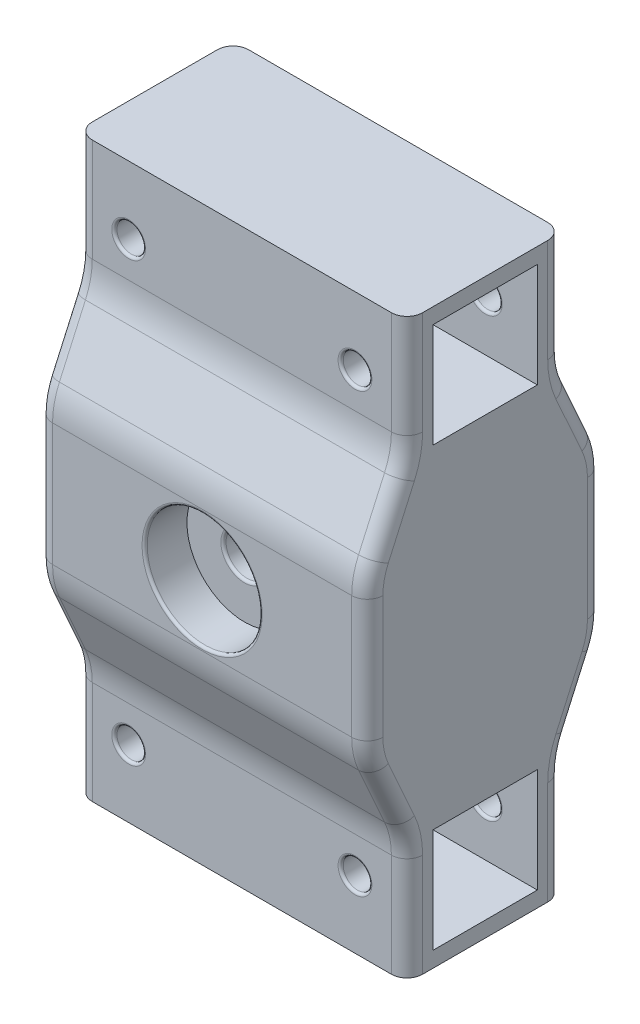
from build123d import *

# Parameters (mm, degrees)
BOSS_EXTRUDE1_DEPTH = 31.75
SKETCH2_R           = 2.75
CUT_EXTRUDE1_DEPTH  = 38.682455813
SKETCH3_R           = 11.049
CUT_EXTRUDE2_DEPTH  = 46.314911625
FILLET1_R           = 0.5
FILLET2_R           = 15
FILLET3_R           = 3
SKETCH4_R           = 11.049
SKETCH4_R_2         = 4.025
BOSS_EXTRUDE2_DEPTH = 14.529456
SKETCH5_R           = 11.049
SKETCH5_R_2         = 4.025
BOSS_EXTRUDE3_DEPTH = 14.529456
FILLET5_R           = 0.5
BOSS_EXTRUDE4_DEPTH = 3


with BuildPart() as part:
    # Sketch1 → Boss-Extrude1 (new body, symmetric)
    with BuildSketch(Plane(origin=(0, 0, 0), x_dir=(0, 0, -1), z_dir=(1, 0, 0))):
        Polygon((-15.025, 32.02), (-22.657455813, 15), (-22.657455813, -15), (-15.025, -32.02), (-15.025, -52.07), (-10.025, -52.07), (-10.025, -32.02), (10.025, -32.02), (10.025, -52.07), (15.025, -52.07), (15.025, -32.02), (22.657455813, -15), (22.657455813, 15), (15.025, 32.02), (15.025, 52.07), (10.025, 52.07), (10.025, 32.02), (-10.025, 32.02), (-10.025, 52.07), (-15.025, 52.07), align=None)
    extrude(amount=BOSS_EXTRUDE1_DEPTH, both=True)

    # Sketch2 → Cut-Extrude1 (cut, through all)
    with BuildSketch(Plane.XY.offset(15.025)):
        with Locations((-21.75, 42.07)):
            Circle(SKETCH2_R)
        with Locations((21.75, 42.07)):
            Circle(SKETCH2_R)
    cut_extrude1 = extrude(amount=-CUT_EXTRUDE1_DEPTH, mode=Mode.SUBTRACT)

    # Mirror1: Cut-Extrude1 across plane
    add(cut_extrude1.mirror(Plane.ZX), mode=Mode.SUBTRACT)

    # Sketch3 → Cut-Extrude2 (cut, through all)
    with BuildSketch(Plane.XY.offset(22.657455813)):
        Circle(SKETCH3_R)
    extrude(amount=-CUT_EXTRUDE2_DEPTH, mode=Mode.SUBTRACT)

    # Fillet1
    fillet1_edges = [part.edges().sort_by_distance(p)[0] for p in [
        (-24.5, 42.07, -10.025),
        (-24.5, 42.07, 10.025),
        (-24.5, 42.07, 15.025),
        (19, 42.07, -10.025),
        (19, 42.07, -15.025),
        (19, 42.07, 10.025),
        (19, 42.07, 15.025),
        (-24.5, -42.07, 15.025),
        (-24.5, -42.07, 10.025),
        (-24.5, -42.07, -10.025),
        (-24.5, -42.07, -15.025),
        (19, -42.07, 15.025),
        (19, -42.07, 10.025),
        (19, -42.07, -10.025),
        (19, -42.07, -15.025),
    ]]
    fillet(fillet1_edges, radius=FILLET1_R)

    # Fillet2
    fillet2_edges = [part.edges().sort_by_distance(p)[0] for p in [
        (0, 32.02, -15.025),
        (0, 15, -22.657455813),
        (0, -15, -22.657455813),
        (0, -32.02, -15.025),
        (0, -32.02, 15.025),
        (0, -15, 22.657455813),
        (0, 15, 22.657455813),
        (0, 32.02, 15.025),
    ]]
    fillet(fillet2_edges, radius=FILLET2_R)

    # Fillet3
    fillet3_edges = [part.edges().sort_by_distance(p)[0] for p in [
        (-31.75, 43.649670271, -15.025),
        (31.75, 43.649670271, -15.025),
        (-31.75, 23.51, -18.841227906),
        (31.75, 23.51, -18.841227906),
        (-31.75, 0, -22.657455813),
        (-31.75, -23.51, -18.841227906),
        (-31.75, -43.649670271, 15.025),
        (-31.75, -23.51, 18.841227906),
        (-31.75, 0, 22.657455813),
        (-31.75, 23.51, 18.841227906),
        (-31.75, 14.928972205, 22.32548203),
        (-31.75, -14.928972205, 22.32548203),
        (-31.75, -14.928972205, -22.32548203),
        (-31.75, 14.928972205, -22.32548203),
        (31.75, 0, -22.657455813),
        (31.75, 23.51, 18.841227906),
        (31.75, 0, 22.657455813),
        (31.75, -23.51, 18.841227906),
        (31.75, -43.649670271, 15.025),
        (31.75, -23.51, -18.841227906),
        (31.75, 14.928972205, 22.32548203),
        (31.75, -14.928972205, 22.32548203),
        (31.75, -14.928972205, -22.32548203),
        (31.75, 14.928972205, -22.32548203),
        (-31.75, 32.091027795, -15.356973783),
        (31.75, 32.091027795, -15.356973783),
        (-31.75, -32.091027795, -15.356973783),
        (31.75, -32.091027795, -15.356973783),
        (-31.75, -32.091027795, 15.356973783),
        (31.75, -32.091027795, 15.356973783),
        (-31.75, 32.091027795, 15.356973783),
        (31.75, 32.091027795, 15.356973783),
        (-31.75, -43.649670271, -15.025),
        (-31.75, 43.649670271, 15.025),
        (31.75, -43.649670271, -15.025),
        (31.75, 43.649670271, 15.025),
    ]]
    fillet(fillet3_edges, radius=FILLET3_R)

    # Sketch4 → Boss-Extrude2 (add)
    with BuildSketch(Plane.XY):
        Circle(SKETCH4_R)
        Circle(SKETCH4_R_2, mode=Mode.SUBTRACT)
    extrude(amount=BOSS_EXTRUDE2_DEPTH)

    # Sketch5 → Boss-Extrude3 (add)
    with BuildSketch(Plane(origin=(0, 0, 0), x_dir=(-1, 0, 0), z_dir=(0, 0, -1))):
        Circle(SKETCH5_R)
        Circle(SKETCH5_R_2, mode=Mode.SUBTRACT)
    extrude(amount=BOSS_EXTRUDE3_DEPTH)

    # Fillet5
    fillet5_edges = [part.edges().sort_by_distance(p)[0] for p in [
        (-4.025, 0, 14.529456),
        (4.025, 0, -14.529456),
        (-11.049, 0, -22.657455813),
        (-11.049, 0, 22.657455813),
    ]]
    fillet(fillet5_edges, radius=FILLET5_R)

    # Sketch6 → Boss-Extrude4 (add)
    with BuildSketch(Plane(origin=(0, 52.07, 0), x_dir=(1, 0, 0), z_dir=(0, 1, 0))):
        with BuildLine():
            Line((-31.75, 10.025), (-31.75, -10.025))
            Line((-31.75, -10.025), (-31.75, -12.025))
            ThreePointArc((-31.75, -12.025), (-30.871320344, -14.146320344), (-28.75, -15.025))
            Line((-28.75, -15.025), (28.75, -15.025))
            ThreePointArc((28.75, -15.025), (30.871320344, -14.146320344), (31.75, -12.025))
            Line((31.75, -12.025), (31.75, -10.025))
            Line((31.75, -10.025), (31.75, 10.025))
            Line((31.75, 10.025), (31.75, 12.025))
            ThreePointArc((31.75, 12.025), (30.871320344, 14.146320344), (28.75, 15.025))
            Line((28.75, 15.025), (-28.75, 15.025))
            ThreePointArc((-28.75, 15.025), (-30.871320344, 14.146320344), (-31.75, 12.025))
            Line((-31.75, 12.025), (-31.75, 10.025))
        make_face()
    boss_extrude4 = extrude(amount=BOSS_EXTRUDE4_DEPTH)

    # Mirror2: Boss-Extrude4 across plane
    add(boss_extrude4.mirror(Plane.ZX))


solid = part.part
